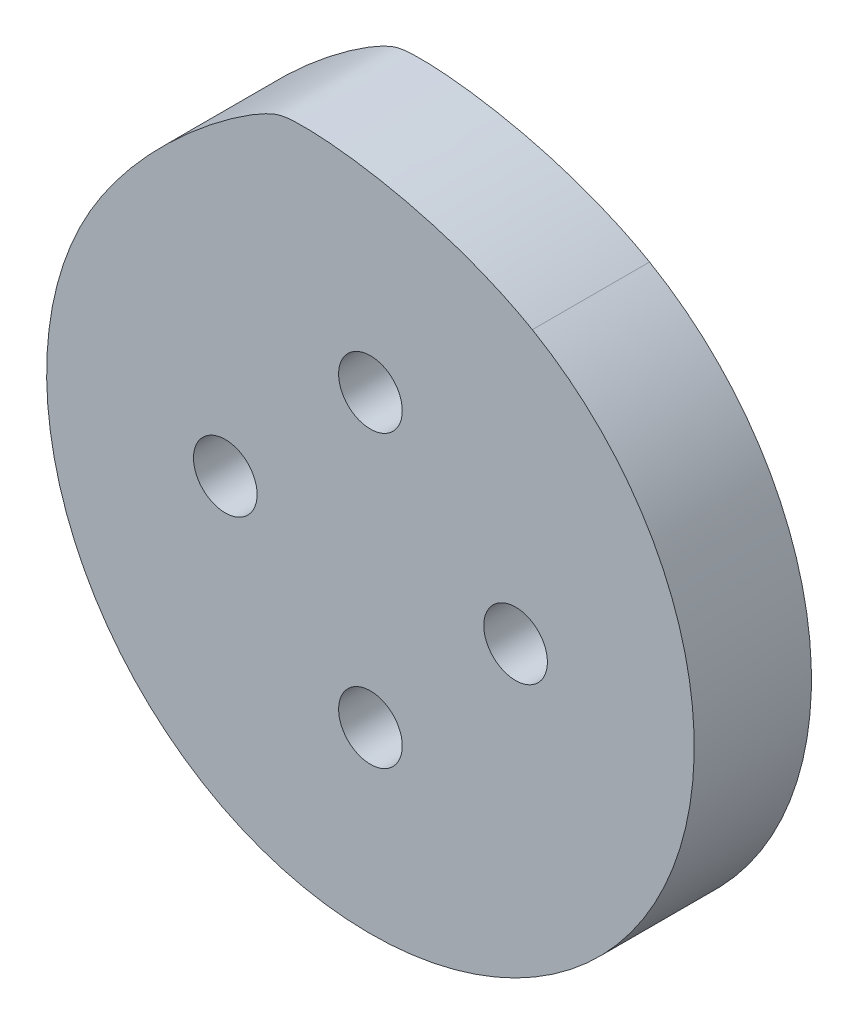
from build123d import *

# Parameters (mm, degrees)
SKETCH1_R               = 21
SKETCH1_R_2             = 2.85
SKETCH1_R_3             = 1.6
BOSS_EXTRUDE1_DEPTH     = 10.5
SKETCH2_R               = 21
BOSS_EXTRUDE3_DEPTH     = 10.5
SKETCH3_R               = 21
SKETCH3_R_2             = 1.6
BOSS_EXTRUDE4_DEPTH     = 0.5
SKETCH4_R               = 2.85
SKETCH4_R_2             = 1.6
CUT_EXTRUDE1_DEPTH      = 1.0000001
CUT_EXTRUDE1_DEPTH_BACK = 8.5


with BuildPart() as part:
    # Sketch1 → Boss-Extrude1 (new body)
    with BuildSketch(Plane(origin=(0, 0, 0), x_dir=(0, 1, 0), z_dir=(0, 0, 1))):
        Circle(SKETCH1_R)
        with Locations((-13, 0)):
            Circle(SKETCH1_R_2, mode=Mode.SUBTRACT)
        with Locations((0, -13)):
            Circle(SKETCH1_R_2, mode=Mode.SUBTRACT)
        with Locations((13, 0)):
            Circle(SKETCH1_R_2, mode=Mode.SUBTRACT)
        with Locations((0, 13)):
            Circle(SKETCH1_R_2, mode=Mode.SUBTRACT)
        with Locations((-13, 0)):
            Circle(SKETCH1_R_2)
        with Locations((-13, 0)):
            Circle(SKETCH1_R_3, mode=Mode.SUBTRACT)
        with Locations((0, 13)):
            Circle(SKETCH1_R_2)
        with Locations((0, 13)):
            Circle(SKETCH1_R_3, mode=Mode.SUBTRACT)
        with Locations((13, 0)):
            Circle(SKETCH1_R_2)
        with Locations((13, 0)):
            Circle(SKETCH1_R_3, mode=Mode.SUBTRACT)
        with Locations((0, -13)):
            Circle(SKETCH1_R_2)
        with Locations((0, -13)):
            Circle(SKETCH1_R_3, mode=Mode.SUBTRACT)
    extrude(amount=BOSS_EXTRUDE1_DEPTH)

    # Sketch2 → Boss-Extrude3 (add)
    with BuildSketch(Plane(origin=(0, 0, 0), x_dir=(1, 0, 0), z_dir=(0, 0, -1))):
        with BuildLine():
            ThreePointArc((14.5, -25.11473671), (25.11473671, -14.5), (29, 0))
            ThreePointArc((29, 0), (-7.505752308, 28.011848962), (-25.11473671, -14.5))
            add(Edge.make_bspline(
                [(-25.11473671, -14.5), (-20.61473671, -22.294228634), (-10.692661327, -29.786053624), (-5.632910469, -31.14180978), (6.705771366, -29.61473671), (14.5, -25.11473671)],
                knots=[0, 0, 0, 0, 0.45, 0.55, 1, 1, 1, 1], degree=3))
        make_face()
        Circle(SKETCH2_R, mode=Mode.SUBTRACT)
    extrude(amount=-BOSS_EXTRUDE3_DEPTH)

    # Sketch3 → Boss-Extrude4 (add)
    with BuildSketch(Plane(origin=(0, 0, 0), x_dir=(1, 0, 0), z_dir=(0, 0, -1))):
        Circle(SKETCH3_R)
        with Locations((-13, 0)):
            Circle(SKETCH3_R_2, mode=Mode.SUBTRACT)
        with Locations((0, 13)):
            Circle(SKETCH3_R_2, mode=Mode.SUBTRACT)
        with Locations((13, 0)):
            Circle(SKETCH3_R_2, mode=Mode.SUBTRACT)
        with Locations((0, -13)):
            Circle(SKETCH3_R_2, mode=Mode.SUBTRACT)
    extrude(amount=BOSS_EXTRUDE4_DEPTH)

    # Sketch4 → Cut-Extrude1 (cut, two sides)
    with BuildSketch(Plane.XY.offset(10.5)) as cut_extrude1_sk:
        with Locations((0, 13)):
            Circle(SKETCH4_R)
        with Locations((0, 13)):
            Circle(SKETCH4_R_2, mode=Mode.SUBTRACT)
        with Locations((13, 0)):
            Circle(SKETCH4_R)
        with Locations((13, 0)):
            Circle(SKETCH4_R_2, mode=Mode.SUBTRACT)
        with Locations((0, -13)):
            Circle(SKETCH4_R)
        with Locations((0, -13)):
            Circle(SKETCH4_R_2, mode=Mode.SUBTRACT)
        with Locations((-13, 0)):
            Circle(SKETCH4_R)
        with Locations((-13, 0)):
            Circle(SKETCH4_R_2, mode=Mode.SUBTRACT)
    extrude(amount=CUT_EXTRUDE1_DEPTH, mode=Mode.SUBTRACT)
    extrude(cut_extrude1_sk.sketch, amount=-CUT_EXTRUDE1_DEPTH_BACK, mode=Mode.SUBTRACT)


solid = part.part
